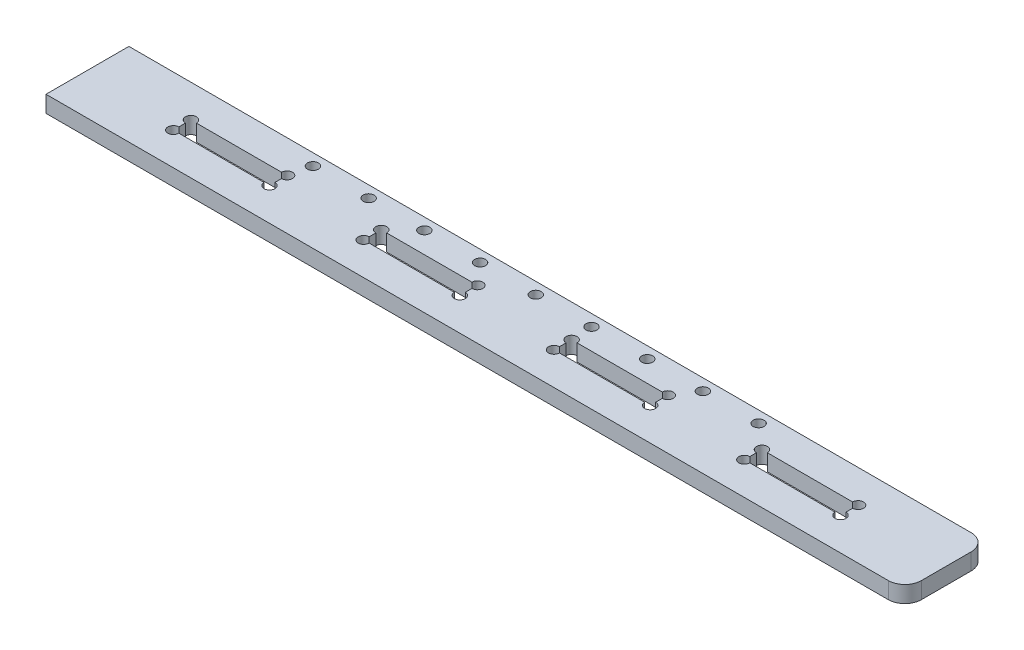
from build123d import *

# Parameters (mm, degrees)
SKETCH1_W           = 259
SKETCH1_H           = 25
BOSS_EXTRUDE1_DEPTH = 5
SKETCH4_W           = 29
SKETCH4_H           = 5.3
CUT_EXTRUDE2_DEPTH  = 6
SKETCH5_R           = 1.65
CUT_EXTRUDE3_DEPTH  = 6
SKETCH6_R           = 1.65
CUT_EXTRUDE4_DEPTH  = 6
FILLET1_R           = 5


with BuildPart() as part:
    # Sketch1 → Boss-Extrude1 (new body)
    with BuildSketch(Plane(origin=(0, 0, 0), x_dir=(1, 0, 0), z_dir=(0, 1, 0))):
        with Locations((129.5, 12.5)):
            Rectangle(SKETCH1_W, SKETCH1_H)
    extrude(amount=BOSS_EXTRUDE1_DEPTH)

    # Sketch4 → Cut-Extrude2 (cut, through all)
    with BuildSketch(Plane(origin=(0, 5, 0), x_dir=(1, 0, 0), z_dir=(0, 1, 0))):
        with Locations((43.05, 12.5)):
            Rectangle(SKETCH4_W, SKETCH4_H)
        with Locations((100.45, 12.5)):
            Rectangle(SKETCH4_W, SKETCH4_H)
        with Locations((157.85, 12.5)):
            Rectangle(SKETCH4_W, SKETCH4_H)
        with Locations((215.25, 12.5)):
            Rectangle(SKETCH4_W, SKETCH4_H)
    extrude(amount=-CUT_EXTRUDE2_DEPTH, mode=Mode.SUBTRACT)

    # Sketch5 → Cut-Extrude3 (cut, through all)
    with BuildSketch(Plane(origin=(0, 5, 0), x_dir=(1, 0, 0), z_dir=(0, 1, 0))):
        with Locations((28.55, 15.15)):
            Circle(SKETCH5_R)
        with Locations((28.55, 9.85)):
            Circle(SKETCH5_R)
        with Locations((57.55, 15.15)):
            Circle(SKETCH5_R)
        with Locations((57.55, 9.85)):
            Circle(SKETCH5_R)
        with Locations((85.95, 15.15)):
            Circle(SKETCH5_R)
        with Locations((85.95, 9.85)):
            Circle(SKETCH5_R)
        with Locations((114.95, 15.15)):
            Circle(SKETCH5_R)
        with Locations((114.95, 9.85)):
            Circle(SKETCH5_R)
        with Locations((143.35, 15.15)):
            Circle(SKETCH5_R)
        with Locations((143.35, 9.85)):
            Circle(SKETCH5_R)
        with Locations((172.35, 15.15)):
            Circle(SKETCH5_R)
        with Locations((172.35, 9.85)):
            Circle(SKETCH5_R)
        with Locations((200.75, 15.15)):
            Circle(SKETCH5_R)
        with Locations((229.75, 15.15)):
            Circle(SKETCH5_R)
        with Locations((229.75, 9.85)):
            Circle(SKETCH5_R)
        with Locations((200.75, 9.85)):
            Circle(SKETCH5_R)
    extrude(amount=-CUT_EXTRUDE3_DEPTH, mode=Mode.SUBTRACT)

    # Sketch6 → Cut-Extrude4 (cut, through all)
    with BuildSketch(Plane.XZ):
        with Locations((193.4, -21.5)):
            Circle(SKETCH6_R)
        with Locations((176.6, -21.5)):
            Circle(SKETCH6_R)
        with Locations((159.8, -21.5)):
            Circle(SKETCH6_R)
        with Locations((143, -21.5)):
            Circle(SKETCH6_R)
        with Locations((126.2, -21.5)):
            Circle(SKETCH6_R)
        with Locations((109.4, -21.5)):
            Circle(SKETCH6_R)
        with Locations((92.6, -21.5)):
            Circle(SKETCH6_R)
        with Locations((75.8, -21.5)):
            Circle(SKETCH6_R)
        with Locations((59, -21.5)):
            Circle(SKETCH6_R)
    extrude(amount=-CUT_EXTRUDE4_DEPTH, mode=Mode.SUBTRACT)

    # Fillet1
    fillet1_edges = [part.edges().sort_by_distance(p)[0] for p in [
        (259, 2.5, -25),
        (259, 2.5, 0),
    ]]
    fillet(fillet1_edges, radius=FILLET1_R)


solid = part.part
